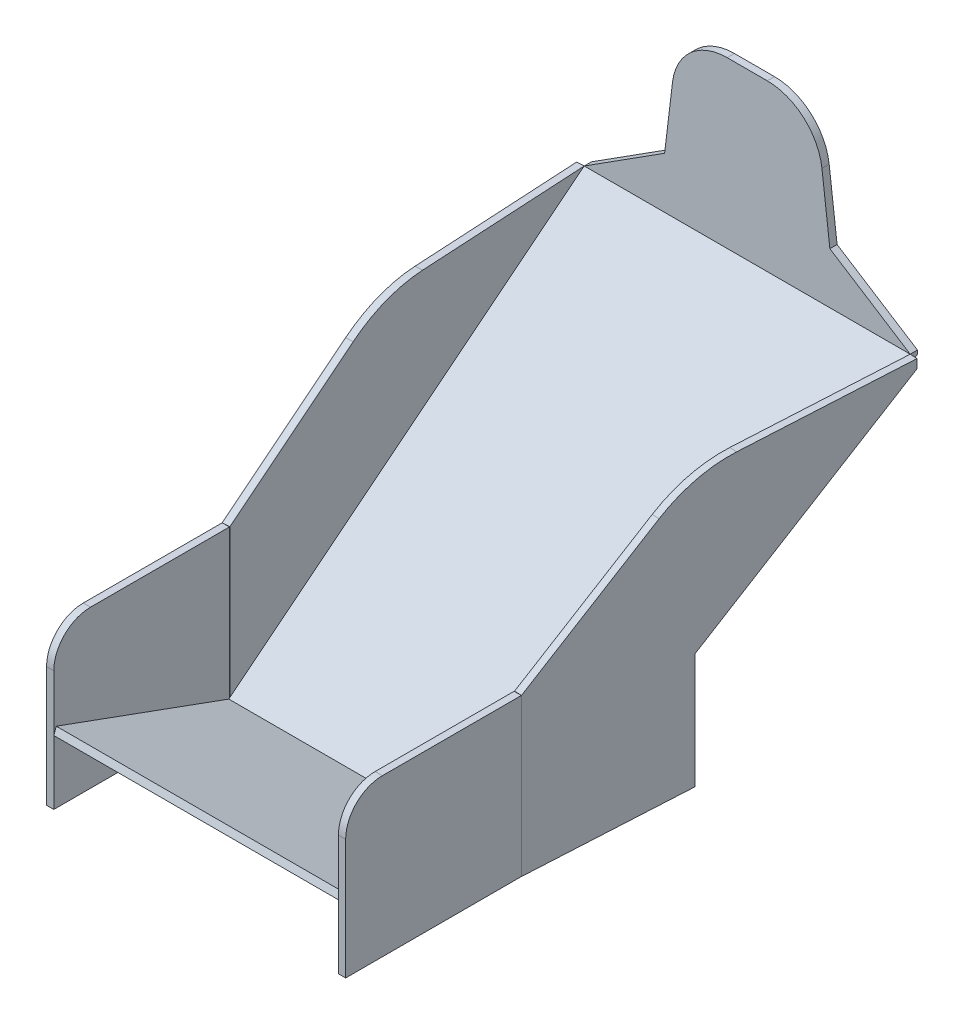
from build123d import *

# Parameters (mm, degrees)
BOSS_EXTRUDE1_DEPTH     = 450.85
CUT_EXTRUDE2_DEPTH      = 508
FILLET1_R               = 76.2
SKETCH8_W               = 28.575
SKETCH8_H               = 250.515691668
CUT_EXTRUDE3_DEPTH      = 244.471906543
CUT_EXTRUDE3_DEPTH_BACK = 361.52650092
BOSS_EXTRUDE4_DEPTH     = 10
SKETCH11_W              = 243.025134326
SKETCH11_H              = 216.946269836
BOSS_EXTRUDE5_DEPTH     = 10
FILLET2_R               = 177.8
FILLET3_R               = 50.8
FILLET2_OF_MIRROR1_R    = 177.8
FILLET3_OF_MIRROR1_R    = 50.8


with BuildPart() as part:
    # Sketch1 → Boss-Extrude1 (new body)
    with BuildSketch(Plane(origin=(0, 0, 0), x_dir=(0, 0, -1), z_dir=(1, 0, 0))):
        Polygon((-172.951120204, -349.34913054), (-411.633045884, -262.476014135), (-415.053247317, -271.872940343), (-171.479591477, -360.52650092), (357.210427919, 9.666236038), (357.210427919, 243.471906543), (347.210427919, 243.471906543), (347.210427919, 14.871906543), align=None)
    extrude(amount=BOSS_EXTRUDE1_DEPTH)

    # Sketch3 → Cut-Extrude2 (cut)
    with BuildSketch(Plane.XY.offset(-347.210427919)):
        Polygon((450.85, 243.471906543), (320.675, 243.471906543), (339.725, 85.650531553), (450.85, 14.871906543), align=None)
        Polygon((111.125, 85.650531553), (130.175, 243.471906543), (0, 243.471906543), (0, 14.871906543), align=None)
    extrude(amount=-CUT_EXTRUDE2_DEPTH, mode=Mode.SUBTRACT)

    # Fillet1
    fillet1_edges = [part.edges().sort_by_distance(p)[0] for p in [
        (320.675, 243.471906543, -352.210427919),
        (130.175, 243.471906543, -352.210427919),
    ]]
    fillet(fillet1_edges, radius=FILLET1_R)

    # Sketch8 → Cut-Extrude3 (cut, two sides)
    with BuildSketch(Plane(origin=(0, 0, 0), x_dir=(1, 0, 0), z_dir=(0, 1, 0))) as cut_extrude3_sk:
        Polygon((0, -172.951120204), (0, 347.210427919), (28.575, -172.951120204), align=None)
        Polygon((422.275, -172.951120204), (450.85, -172.951120204), (450.85, 347.210427919), align=None)
        with Locations((436.5625, -298.208966038)):
            Rectangle(SKETCH8_W, SKETCH8_H)
        with Locations((14.2875, -298.208966038)):
            Rectangle(SKETCH8_W, SKETCH8_H)
    extrude(amount=CUT_EXTRUDE3_DEPTH, mode=Mode.SUBTRACT)
    extrude(cut_extrude3_sk.sketch, amount=-CUT_EXTRUDE3_DEPTH_BACK, mode=Mode.SUBTRACT)

    # Sketch9 → Boss-Extrude4 (add)
    with BuildSketch(Plane(origin=(19.016566107, 0, -1.04467233), x_dir=(0.054852151, 0, 0.998494487), z_dir=(-0.998494487, 0, 0.054852151))):
        Polygon((-53.849912427, 14.871906543), (-346.687698266, 14.871906543), (172.784392877, -348.318755032), (172.784392877, -143.580231084), align=None)
        Polygon((172.784392877, -360.52650092), (-55.252957085, -201.093419897), (-55.252957085, -360.52650092), align=None)
        Polygon((172.784392877, -348.318755032), (-346.687698266, 14.871906543), (-346.687698266, 2.664160656), (-55.252957085, -201.093419897), (172.784392877, -360.52650092), align=None)
    boss_extrude4 = extrude(amount=BOSS_EXTRUDE4_DEPTH)

    # Sketch11 → Boss-Extrude5 (add)
    with BuildSketch(Plane.ZY.offset(-28.575)):
        with Locations((293.540680154, -252.053366002)):
            Rectangle(SKETCH11_W, SKETCH11_H)
    boss_extrude5 = extrude(amount=BOSS_EXTRUDE5_DEPTH)

    # Fillet2
    fillet2_edges = [part.edges().sort_by_distance(p)[0] for p in [
        (11.070310121, 14.871906543, -54.539252282),
    ]]
    fillet(fillet2_edges, radius=FILLET2_R)

    # Fillet3
    fillet3_edges = [part.edges().sort_by_distance(p)[0] for p in [
        (23.575, -143.580231084, 415.053247317),
    ]]
    fillet(fillet3_edges, radius=FILLET3_R)

    # Mirror1: Boss-Extrude4, Boss-Extrude5 across plane
    add(boss_extrude4.mirror(Plane(origin=(225.425, 0, 0), x_dir=(0, 0, 1), z_dir=(1, 0, 0))))
    add(boss_extrude5.mirror(Plane(origin=(225.425, 0, 0), x_dir=(0, 0, 1), z_dir=(1, 0, 0))))

    # Fillet2 of Mirror1
    fillet2_of_mirror1_edges = [part.edges().sort_by_distance(p)[0] for p in [
        (439.779689879, 14.871906543, -54.539252282),
    ]]
    fillet(fillet2_of_mirror1_edges, radius=FILLET2_OF_MIRROR1_R)

    # Fillet3 of Mirror1
    fillet3_of_mirror1_edges = [part.edges().sort_by_distance(p)[0] for p in [
        (427.275, -143.580231084, 415.053247317),
    ]]
    fillet(fillet3_of_mirror1_edges, radius=FILLET3_OF_MIRROR1_R)


solid = part.part
